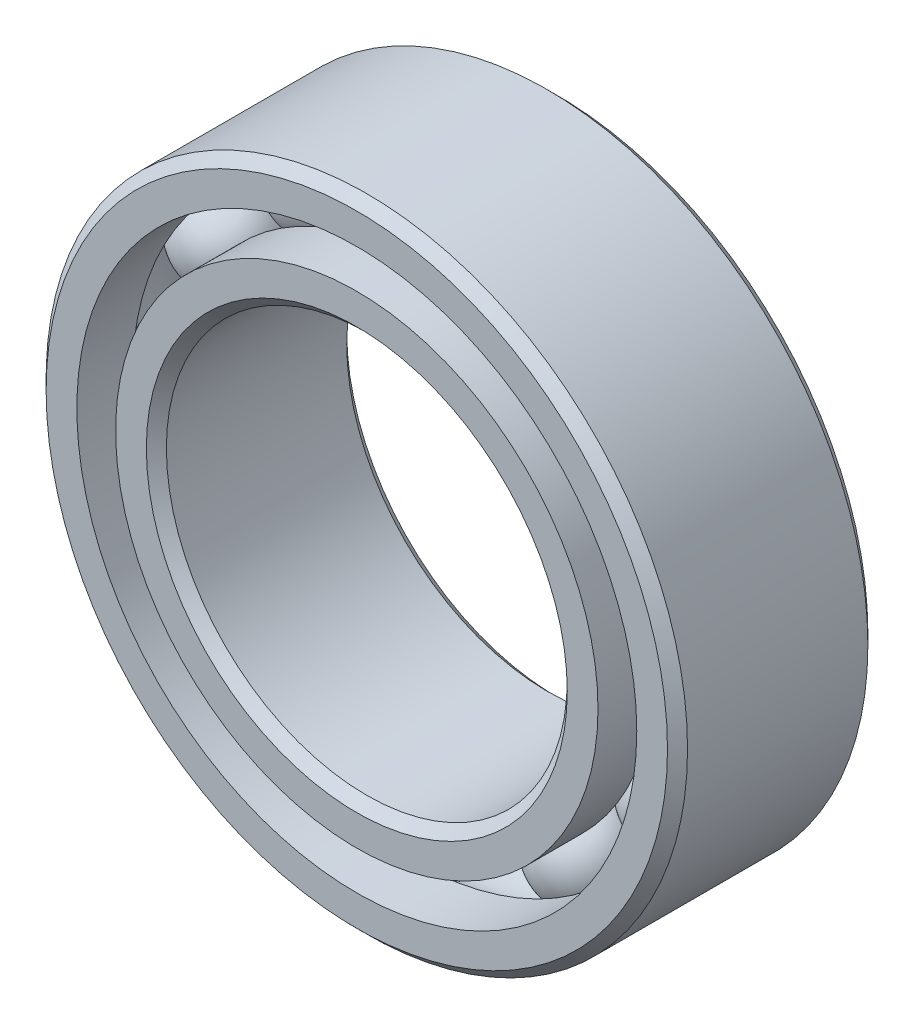
from build123d import *

# Parameters (mm, degrees)
CIRPATTERN1_COUNT = 12


with BuildPart() as part:
    # Sketch1 → Revolve1 (revolve)
    with BuildSketch(Plane(origin=(0, 0, 0), x_dir=(0, 0, -1), z_dir=(1, 0, 0)), mode=Mode.PRIVATE) as revolve1_sk:
        with BuildLine():
            Line((1.785366, 6.35), (-1.785366, 6.35))
            Line((-1.785366, 6.35), (-1.98374, 6.151626))
            Line((-1.98374, 6.151626), (-1.98374, 5.543222033))
            Line((-1.98374, 5.543222033), (-0.881662222, 5.543222033))
            ThreePointArc((-0.881662222, 5.543222033), (0, 6.120970975), (0.881662222, 5.543222033))
            Line((0.881662222, 5.543222033), (1.98374, 5.543222033))
            Line((1.98374, 5.543222033), (1.98374, 6.151626))
            Line((1.98374, 6.151626), (1.785366, 6.35))
        make_face()
    revolve(revolve1_sk.sketch.rotate(Axis((0, 0, 1.98374), (0, 0, -1)), 90), axis=Axis((0, 0, 1.98374), (0, 0, -1)))  # turned: the seam where the file's is


with BuildPart() as body_2:
    # Sketch3 → Revolve3 (revolve)
    with BuildSketch(Plane(origin=(0, 0, 0), x_dir=(0, 0, -1), z_dir=(1, 0, 0)), mode=Mode.PRIVATE) as revolve3_sk:
        with BuildLine():
            Line((-1.98374, 4.775527967), (-0.881662222, 4.775527967))
            ThreePointArc((-0.881662222, 4.775527967), (0, 4.197779025), (0.881662222, 4.775527967))
            Line((0.881662222, 4.775527967), (1.98374, 4.775527967))
            Line((1.98374, 4.775527967), (1.98374, 4.167124))
            Line((1.98374, 4.167124), (1.785366, 3.96875))
            Line((1.785366, 3.96875), (-1.785366, 3.96875))
            Line((-1.785366, 3.96875), (-1.98374, 4.167124))
            Line((-1.98374, 4.167124), (-1.98374, 4.775527967))
        make_face()
    revolve(revolve3_sk.sketch.rotate(Axis((0, 0, 1.98374), (0, 0, -1)), 90), axis=Axis((0, 0, 1.98374), (0, 0, -1)))  # turned: the seam where the file's is


with BuildPart() as body_3:
    # Sketch4 → Revolve4 (revolve)
    with BuildSketch(Plane(origin=(0, 0, 0), x_dir=(0, 0, -1), z_dir=(1, 0, 0))):
        with BuildLine():
            Line((-0.961595975, 5.159375), (0.961595975, 5.159375))
            ThreePointArc((0.961595975, 5.159375), (0, 6.120970975), (-0.961595975, 5.159375))
        make_face()
    revolve(axis=Axis((0, 5.159375, 0.961595975), (0, 0, -1)))


with BuildPart() as cirpattern1_1:
    # CirPattern1: pattern copy
    add(body_3.part.rotate(Axis((0, 0, 0), (0, 0, 1)), 1 * 360 / CIRPATTERN1_COUNT))


with BuildPart() as cirpattern1_2:
    # CirPattern1: pattern copy
    add(body_3.part.rotate(Axis((0, 0, 0), (0, 0, 1)), 2 * 360 / CIRPATTERN1_COUNT))


with BuildPart() as cirpattern1_3:
    # CirPattern1: pattern copy
    add(body_3.part.rotate(Axis((0, 0, 0), (0, 0, 1)), 3 * 360 / CIRPATTERN1_COUNT))


with BuildPart() as cirpattern1_4:
    # CirPattern1: pattern copy
    add(body_3.part.rotate(Axis((0, 0, 0), (0, 0, 1)), 4 * 360 / CIRPATTERN1_COUNT))


with BuildPart() as cirpattern1_5:
    # CirPattern1: pattern copy
    add(body_3.part.rotate(Axis((0, 0, 0), (0, 0, 1)), 5 * 360 / CIRPATTERN1_COUNT))


with BuildPart() as cirpattern1_6:
    # CirPattern1: pattern copy
    add(body_3.part.rotate(Axis((0, 0, 0), (0, 0, 1)), 6 * 360 / CIRPATTERN1_COUNT))


with BuildPart() as cirpattern1_7:
    # CirPattern1: pattern copy
    add(body_3.part.rotate(Axis((0, 0, 0), (0, 0, 1)), 7 * 360 / CIRPATTERN1_COUNT))


with BuildPart() as cirpattern1_8:
    # CirPattern1: pattern copy
    add(body_3.part.rotate(Axis((0, 0, 0), (0, 0, 1)), 8 * 360 / CIRPATTERN1_COUNT))


with BuildPart() as cirpattern1_9:
    # CirPattern1: pattern copy
    add(body_3.part.rotate(Axis((0, 0, 0), (0, 0, 1)), 9 * 360 / CIRPATTERN1_COUNT))


with BuildPart() as cirpattern1_10:
    # CirPattern1: pattern copy
    add(body_3.part.rotate(Axis((0, 0, 0), (0, 0, 1)), 10 * 360 / CIRPATTERN1_COUNT))


with BuildPart() as cirpattern1_11:
    # CirPattern1: pattern copy
    add(body_3.part.rotate(Axis((0, 0, 0), (0, 0, 1)), 11 * 360 / CIRPATTERN1_COUNT))


solid = Compound([part.part, body_2.part, body_3.part, cirpattern1_1.part, cirpattern1_2.part, cirpattern1_3.part, cirpattern1_4.part, cirpattern1_5.part, cirpattern1_6.part, cirpattern1_7.part, cirpattern1_8.part, cirpattern1_9.part, cirpattern1_10.part, cirpattern1_11.part])
